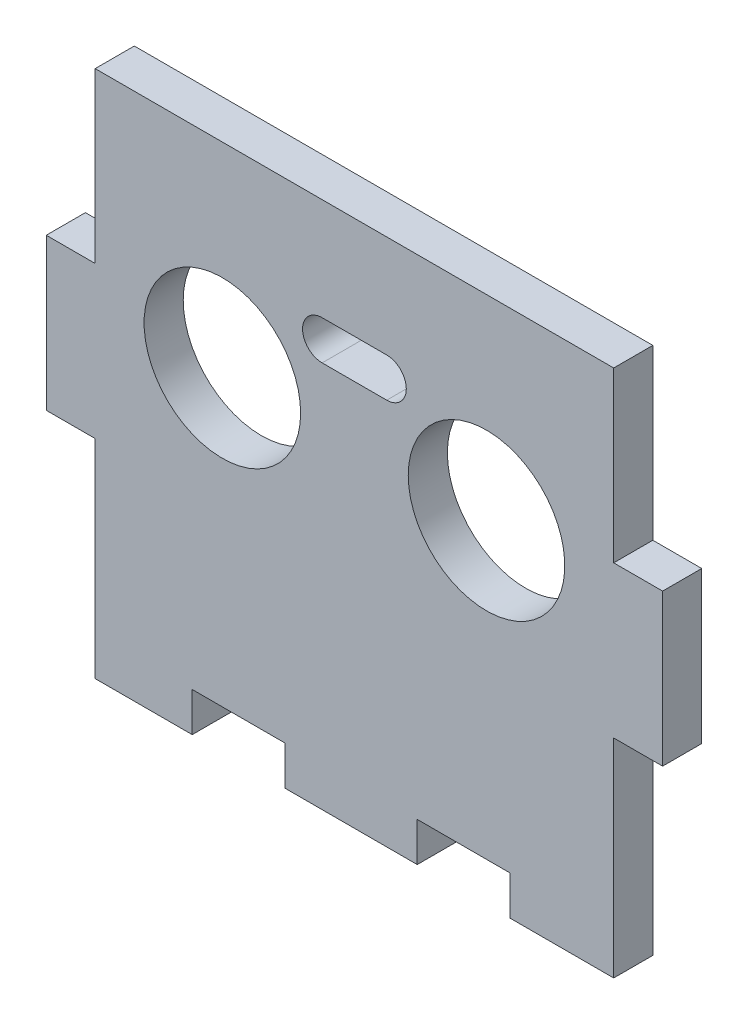
from build123d import *

# Parameters (mm, degrees)
SKIZZE1_W                       = 63
SKIZZE1_H                       = 54
AUFSATZ_LINEAR_AUSTRAGEN1_DEPTH = 4
SCHNITT_LINEAR_AUSTRAGEN3_REACH = 6
SKIZZE4_W                       = 9.5
SKIZZE4_H                       = 4
SKIZZE2_W                       = 5
SKIZZE2_H                       = 17.25
SKIZZE2_H_2                     = 21.25
SCHNITT_LINEAR_AUSTRAGEN1_DEPTH = 4
SKIZZE5_R                       = 8
SCHNITT_LINEAR_AUSTRAGEN4_DEPTH = 4


with BuildPart() as part:
    # Skizze1 → Aufsatz-Linear austragen1 (new body)
    with BuildSketch(Plane.XY):
        with Locations((31.5, 27)):
            Rectangle(SKIZZE1_W, SKIZZE1_H)
    extrude(amount=AUFSATZ_LINEAR_AUSTRAGEN1_DEPTH)

    # Skizze4 → Schnitt-Linear austragen3 (cut, up to next)
    with BuildSketch(Plane.XY.offset(4), mode=Mode.PRIVATE) as schnitt_linear_austragen3_sk1:
        with Locations((19.669225385, 2)):
            Rectangle(SKIZZE4_W, SKIZZE4_H)
    schnitt_linear_austragen3_tool1 = extrude(schnitt_linear_austragen3_sk1.sketch, amount=-SCHNITT_LINEAR_AUSTRAGEN3_REACH, mode=Mode.PRIVATE) & part.part
    add(schnitt_linear_austragen3_tool1.solids().sort_by_distance((19.669225, 2, 4))[0], mode=Mode.SUBTRACT)
    # Skizze4 → Schnitt-Linear austragen3 (cut, up to next)
    with BuildSketch(Plane.XY.offset(4), mode=Mode.PRIVATE) as schnitt_linear_austragen3_sk2:
        with Locations((42.669225385, 2)):
            Rectangle(SKIZZE4_W, SKIZZE4_H)
    schnitt_linear_austragen3_tool2 = extrude(schnitt_linear_austragen3_sk2.sketch, amount=-SCHNITT_LINEAR_AUSTRAGEN3_REACH, mode=Mode.PRIVATE) & part.part
    add(schnitt_linear_austragen3_tool2.solids().sort_by_distance((42.669225, 2, 4))[0], mode=Mode.SUBTRACT)

    # Skizze2 → Schnitt-Linear austragen1 (cut)
    with BuildSketch(Plane.XY.offset(4)):
        with Locations((2.5, 45.375)):
            Rectangle(SKIZZE2_W, SKIZZE2_H)
        with Locations((2.5, 10.625)):
            Rectangle(SKIZZE2_W, SKIZZE2_H_2)
    schnitt_linear_austragen1 = extrude(amount=-SCHNITT_LINEAR_AUSTRAGEN1_DEPTH, mode=Mode.SUBTRACT)

    # Spiegeln1: Schnitt-Linear austragen1 across plane
    add(schnitt_linear_austragen1.mirror(Plane.ZY.offset(-31.5)), mode=Mode.SUBTRACT)

    # Skizze5 → Schnitt-Linear austragen4 (cut)
    with BuildSketch(Plane.XY.offset(4)):
        with Locations((18, 34)):
            Circle(SKIZZE5_R)
        with BuildLine():
            Line((31.5, 43.55), (28.2, 43.55))
            ThreePointArc((28.2, 43.55), (26.2, 41.55), (28.2, 39.55))
            Line((28.2, 39.55), (31.5, 39.55))
            Line((31.5, 39.55), (31.5, 43.55))
        make_face()
    schnitt_linear_austragen4 = extrude(amount=-SCHNITT_LINEAR_AUSTRAGEN4_DEPTH, mode=Mode.SUBTRACT)

    # Spiegeln2: Schnitt-Linear austragen4 across plane
    add(schnitt_linear_austragen4.mirror(Plane.ZY.offset(-31.5)), mode=Mode.SUBTRACT)


solid = part.part
